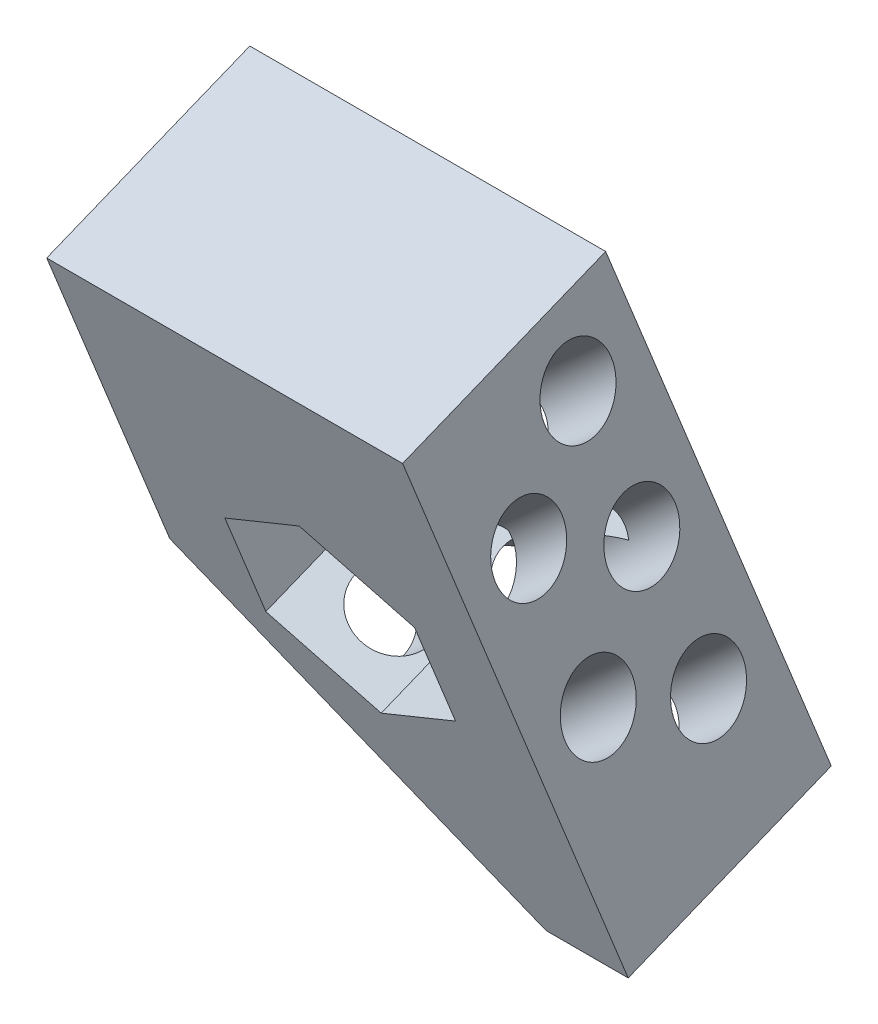
from build123d import *

# Parameters (mm, degrees)
SKETCH1_W           = 110
SKETCH1_H           = 65
BOSS_EXTRUDE1_DEPTH = 40
CHAMFER1_SIZE       = 50
SKETCH2_R           = 6.5
CUT_EXTRUDE1_DEPTH  = 99.212300536
CUT_EXTRUDE2_DEPTH  = 79.206210375


with BuildPart() as part:
    # Sketch1 → Boss-Extrude1 (new body)
    with BuildSketch(Plane(origin=(0, 0, 0), x_dir=(0, -0.927183855, -0.374606593), z_dir=(0, 0.374606593, -0.927183855))):
        with Locations((55, 32.5)):
            Rectangle(SKETCH1_W, SKETCH1_H)
    extrude(amount=BOSS_EXTRUDE1_DEPTH)

    # Chamfer1
    chamfer1_edges = [part.edges().sort_by_distance(p)[0] for p in [
        (-65, -94.498092134, -59.750402367),
    ]]
    chamfer(chamfer1_edges, length=CHAMFER1_SIZE)

    # Sketch2 → Cut-Extrude1 (cut, through all)
    with BuildSketch(Plane(origin=(-62.5, -57.94899091, -23.412912088), x_dir=(0.194241708, 0.180097776, -0.964279498), z_dir=(-0.707106781, -0.655617991, -0.264886862))):
        with Locations((24.302116706, 41.380596093)):
            Circle(SKETCH2_R)
        with Locations((36.115509488, 24.485515419)):
            Circle(SKETCH2_R)
        with Locations((17.709334516, 18.30387139)):
            Circle(SKETCH2_R)
        with Locations((30.072125815, 3.331851109)):
            Circle(SKETCH2_R)
        with Locations((42.43359242, 46.600709926)):
            Circle(SKETCH2_R)
    extrude(amount=-CUT_EXTRUDE1_DEPTH, mode=Mode.SUBTRACT)

    # Sketch3 → Cut-Extrude2 (cut, through all)
    with BuildSketch(Plane(origin=(0, 14.984263737, -37.087354183), x_dir=(0, -0.927183855, -0.374606593), z_dir=(0, 0.374606593, -0.927183855))):
        Polygon((45, 14.679491924), (65, 14.679491924), (75, 32), (65, 49.320508076), (45, 49.320508076), (35, 32), align=None)
    extrude(amount=-CUT_EXTRUDE2_DEPTH, mode=Mode.SUBTRACT)


solid = part.part
